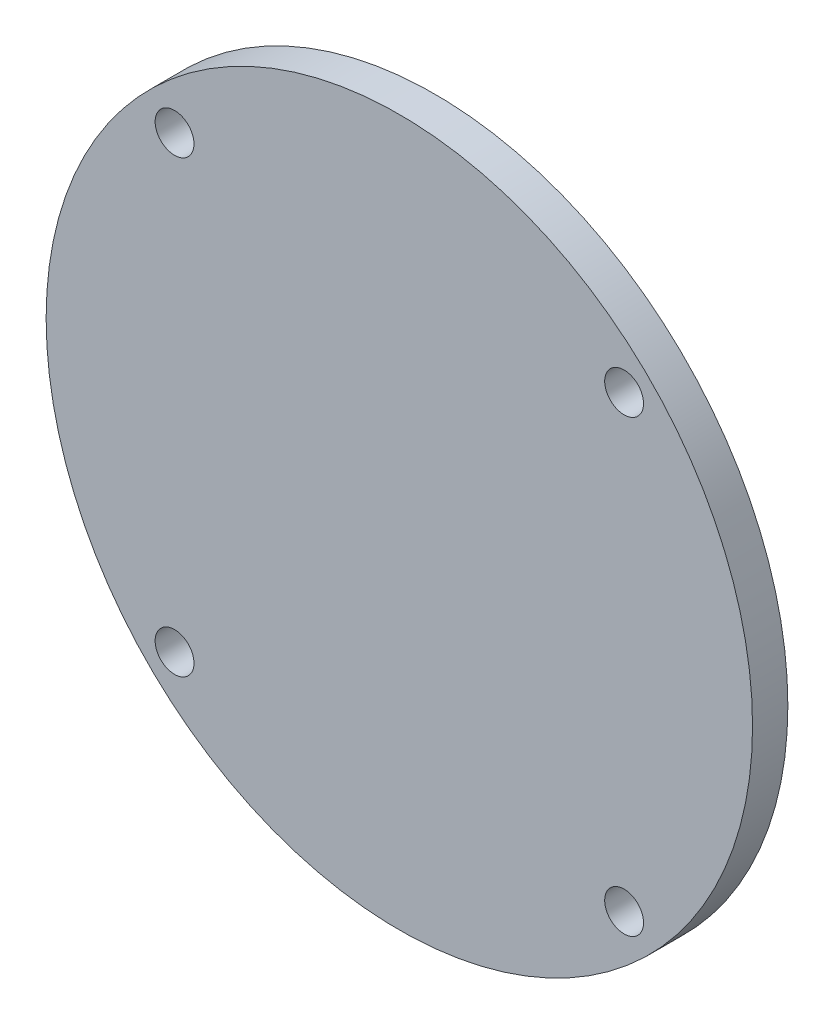
from build123d import *

# Parameters (mm, degrees)
SKETCH1_R                 = 50
EXTRUDE1_DEPTH            = 5
M5_5_5_5_DIAMETER_HOLE2_D = 5.5


with BuildPart() as part:
    # Sketch1 → Extrude1 (new body)
    with BuildSketch(Plane.XY):
        Circle(SKETCH1_R)
    extrude(amount=-EXTRUDE1_DEPTH)

    # M5.5 (5.5) Diameter Hole2 (through all)
    with Locations(Plane.XY):
        with Locations((-31.819805153, 31.819805153), (31.819805153, 31.819805153), (31.819805153, -31.819805153), (-31.819805153, -31.819805153)):
            Hole(M5_5_5_5_DIAMETER_HOLE2_D / 2)


solid = part.part
